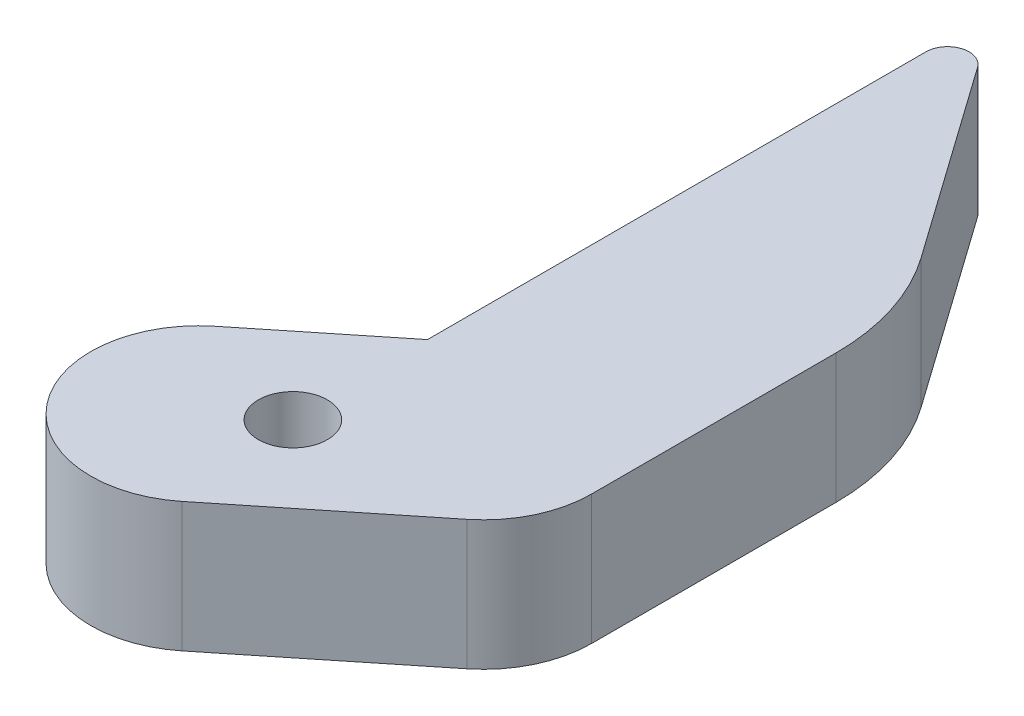
from build123d import *

# Parameters (mm, degrees)
ESBO_O1_R                = 1.6
RESSALTO_EXTRUS_O1_DEPTH = 6
RESSALTO_EXTRUS_O2_DEPTH = 6
FILETE1_R                = 10


with BuildPart() as part:
    # Esboço1 → Ressalto-extrusão1 (new body)
    with BuildSketch(Plane.XZ.offset(12)):
        with BuildLine():
            Line((-5.554408486, -1.950425304), (-0.098401843, -6.33585476))
            Line((-0.098401843, -6.33585476), (-0.098401843, -23.434191187))
            ThreePointArc((-0.098401843, -23.434191187), (0.884517689, -24.84224935), (2.545101876, -24.404963685))
            ThreePointArc((2.545101876, -24.404963685), (6.090429059, -19.835978921), (9.220727662, -14.973243345))
            ThreePointArc((9.220727662, -14.973243345), (9.728380083, -13.758965882), (9.901598157, -12.454291119))
            Line((9.901598157, -12.454291119), (9.901598157, -3.939806958))
            ThreePointArc((9.901598157, -3.939806958), (9.410602928, -1.779048764), (8.034047768, -0.042659356))
            Line((8.034047768, -0.042659356), (0.710490736, 5.843869901))
            ThreePointArc((0.710490736, 5.843869901), (-6.319106477, 5.07917191), (-5.554408486, -1.950425304))
        make_face()
        Circle(ESBO_O1_R, mode=Mode.SUBTRACT)
    extrude(amount=-RESSALTO_EXTRUS_O1_DEPTH)

    # Esboço2 → Ressalto-extrusão2 (add)
    with BuildSketch(Plane.XZ.offset(12)):
        with BuildLine():
            ThreePointArc((2.545101876, -24.404963685), (0.884517689, -24.84224935), (-0.098401843, -23.434191187))
            Line((-0.098401843, -23.434191187), (-0.098401843, -29.434191187))
            ThreePointArc((-0.098401843, -29.434191187), (0.598477482, -30.387143367), (1.71783387, -30.011910201))
            Line((1.71783387, -30.011910201), (9.901598157, -18.449402273))
            Line((9.901598157, -18.449402273), (9.901598157, -12.454291119))
            ThreePointArc((9.901598157, -12.454291119), (9.728380083, -13.758965882), (9.220727662, -14.973243345))
            ThreePointArc((9.220727662, -14.973243345), (6.090429059, -19.835978921), (2.545101876, -24.404963685))
        make_face()
    extrude(amount=-RESSALTO_EXTRUS_O2_DEPTH)

    # Filete1
    filete1_edges = [part.edges().sort_by_distance(p)[0] for p in [
        (9.901598157, -9, -18.449402273),
    ]]
    fillet(filete1_edges, radius=FILETE1_R)


solid = part.part
